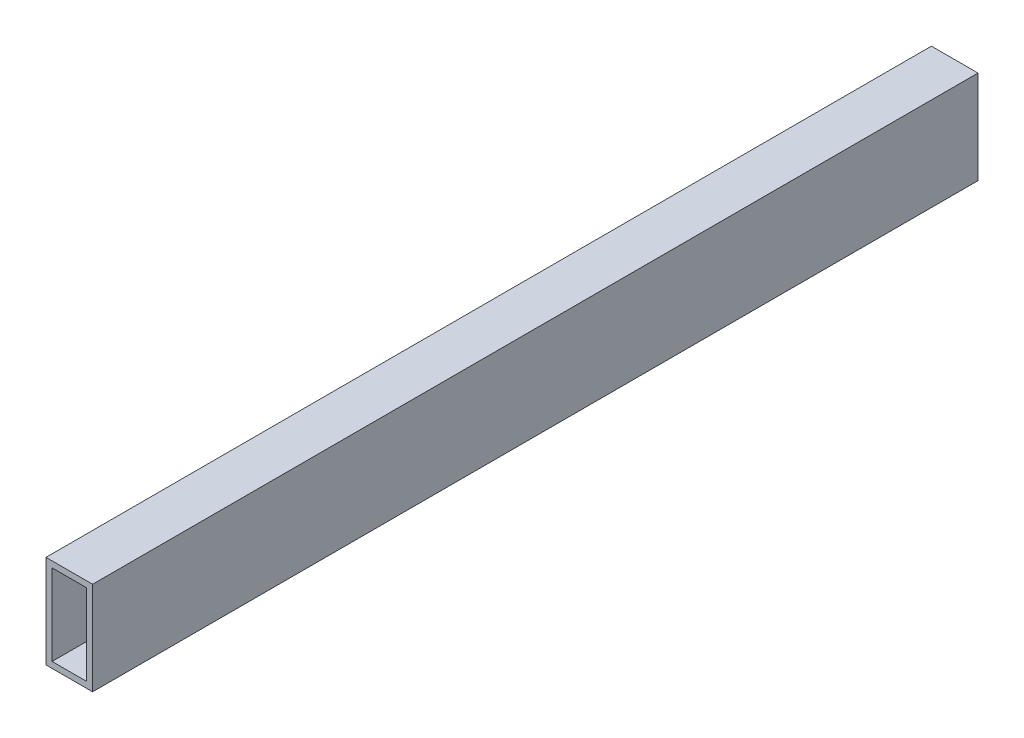
from build123d import *

# Parameters (mm, degrees)
SKETCH1_W           = 25.4
SKETCH1_H           = 50.8
SKETCH1_W_2         = 18.796
SKETCH1_H_2         = 44.196
BOSS_EXTRUDE1_DEPTH = 482.6


with BuildPart() as part:
    # Sketch1 → Boss-Extrude1 (new body)
    with BuildSketch(Plane.XY):
        Rectangle(SKETCH1_W, SKETCH1_H)
        Rectangle(SKETCH1_W_2, SKETCH1_H_2, mode=Mode.SUBTRACT)
    extrude(amount=BOSS_EXTRUDE1_DEPTH)


solid = part.part
